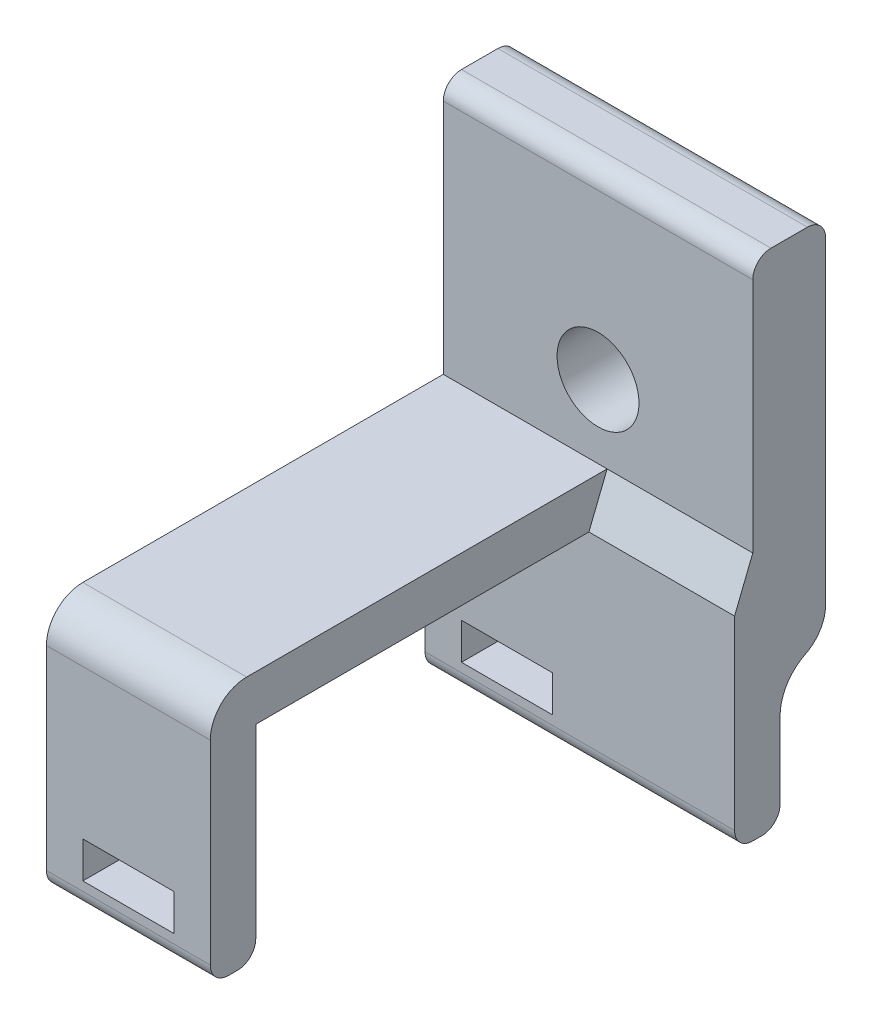
from build123d import *

# Parameters (mm, degrees)
BOSS_EXTRUDE1_DEPTH      = 4.5
FILLET1_R                = 2
BOSS_EXTRUDE2_DEPTH      = 8
M4_CLEARANCE_HOLE1_D     = 4.5
M4_CLEARANCE_HOLE1_DEPTH = 12.4
M4_CLEARANCE_HOLE1_TIP   = 1.351936393
SKETCH9_W                = 9
SKETCH9_H                = 3.5
BOSS_EXTRUDE3_DEPTH      = 2.5
SKETCH10_W               = 17
SKETCH10_H               = 3.5
BOSS_EXTRUDE4_DEPTH      = 2.5
SKETCH11_W               = 5
SKETCH11_H               = 2
CUT_EXTRUDE1_DEPTH       = 26.8
FILLET2_R                = 1


with BuildPart() as part:
    # Sketch3 → Boss-Extrude1 (new body, symmetric)
    with BuildSketch(Plane(origin=(0, 0, 0), x_dir=(0, 0, -1), z_dir=(1, 0, 0))):
        with BuildLine():
            Line((-23.3, -14.200000018), (-23.3, -6.5))
            Line((-23.3, -6.5), (-5, -6.5))
            Line((-5, -6.5), (-5, -14.200000018))
            Line((-5, -14.200000018), (-2.5, -14.200000018))
            Line((-2.5, -14.200000018), (-2.5, -12.5))
            ThreePointArc((-2.5, -12.5), (-1.767766953, -10.732233047), (0, -10))
            Line((0, -10), (0, 10))
            Line((0, 10), (-4, 10))
            Line((-4, 10), (-4, -4))
            Line((-4, -4), (-25.8, -4))
            Line((-25.8, -4), (-25.8, -14.200000018))
            Line((-25.8, -14.200000018), (-23.3, -14.200000018))
        make_face()
    extrude(amount=BOSS_EXTRUDE1_DEPTH, both=True)

    # Fillet1
    fillet1_edges = [part.edges().sort_by_distance(p)[0] for p in [
        (0, -10, 0),
        (0, -4, 25.8),
    ]]
    fillet(fillet1_edges, radius=FILLET1_R)

    # Sketch8 → Boss-Extrude2 (add)
    with BuildSketch(Plane(origin=(4.5, 0, 0), x_dir=(0, 0, -1), z_dir=(1, 0, 0))):
        with BuildLine():
            Line((-4, -4), (-5, -6.5))
            Line((-5, -6.5), (-5, -14.200000018))
            Line((-5, -14.200000018), (-2.5, -14.200000018))
            Line((-2.5, -14.200000018), (-2.5, -12.5))
            ThreePointArc((-2.5, -12.5), (-2.124591464, -11.182384308), (-1.111111111, -10.260483959))
            ThreePointArc((-1.111111111, -10.260483959), (-0.300326829, -9.522963679), (0, -8.468871126))
            Line((0, -8.468871126), (0, 10))
            Line((0, 10), (-4, 10))
            Line((-4, 10), (-4, -4))
        make_face()
    extrude(amount=BOSS_EXTRUDE2_DEPTH)

    # M4 Clearance Hole1
    with Locations(Plane(origin=(0, 0, 0), x_dir=(1, 0, 0), z_dir=(0, 0, -1))):
        with Locations((4, 0)):
            Hole(M4_CLEARANCE_HOLE1_D / 2, depth=M4_CLEARANCE_HOLE1_DEPTH)
            with Locations((0, 0, -(M4_CLEARANCE_HOLE1_DEPTH + M4_CLEARANCE_HOLE1_TIP / 2))):  # 118° drill point
                Cone(0, M4_CLEARANCE_HOLE1_D / 2, M4_CLEARANCE_HOLE1_TIP, mode=Mode.SUBTRACT)

    # Sketch9 → Boss-Extrude3 (add)
    with BuildSketch(Plane.XY.offset(25.8)):
        with Locations((0, -15.950000018)):
            Rectangle(SKETCH9_W, SKETCH9_H)
    extrude(amount=-BOSS_EXTRUDE3_DEPTH)

    # Sketch10 → Boss-Extrude4 (add)
    with BuildSketch(Plane.XY.offset(5)):
        with Locations((4, -15.950000018)):
            Rectangle(SKETCH10_W, SKETCH10_H)
    extrude(amount=-BOSS_EXTRUDE4_DEPTH)

    # Sketch11 → Cut-Extrude1 (cut, through all)
    with BuildSketch(Plane.XY.offset(25.8)):
        with Locations((0, -15.200000018)):
            Rectangle(SKETCH11_W, SKETCH11_H)
    extrude(amount=-CUT_EXTRUDE1_DEPTH, mode=Mode.SUBTRACT)

    # Fillet2
    fillet2_edges = [part.edges().sort_by_distance(p)[0] for p in [
        (4, 10, 0),
        (4, 10, 4),
        (0, -17.700000018, 25.8),
        (0, -17.700000018, 23.3),
        (4, -17.700000018, 5),
        (4, -17.700000018, 2.5),
    ]]
    fillet(fillet2_edges, radius=FILLET2_R)


solid = part.part
